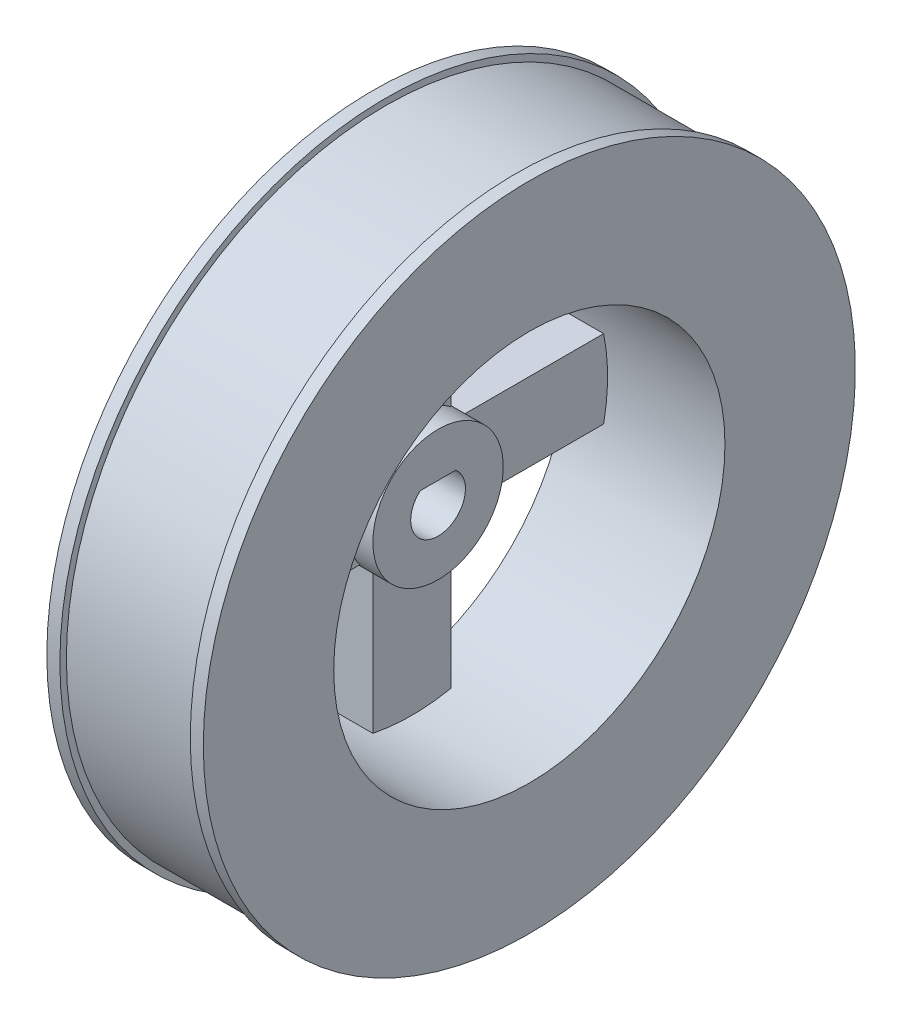
from build123d import *

# Parameters (mm, degrees)
SKETCH1_W               = 5
SKETCH1_H               = 5
BOSS_EXTRUDE1_DEPTH     = 3
CUT_EXTRUDE1_DEPTH      = 8
CUT_EXTRUDE1_DEPTH_BACK = 6
CIRPATTERN1_COUNT       = 4


with BuildPart() as part:
    # Sketch1 → Revolve1 (revolve)
    with BuildSketch(Plane.XY):
        Polygon((-6, 25), (-6, 15), (6, 15), (6, 25), (5, 25), (5, 24.5), (-5, 24.5), (-5, 25), align=None)
        with Locations((-3.5, 2.5)):
            Rectangle(SKETCH1_W, SKETCH1_H)
    revolve(axis=Axis((0, 0, 0), (1, 0, 0)))

    # Sketch2 → Boss-Extrude1 (add)
    with BuildSketch(Plane(origin=(-6, 0, 0), x_dir=(0, 0, -1), z_dir=(1, 0, 0))):
        with BuildLine():
            Line((-3, 4), (-3, 14.696938457))
            ThreePointArc((-3, 14.696938457), (0, 15), (3, 14.696938457))
            Line((3, 14.696938457), (3, 4))
            ThreePointArc((3, 4), (0, 5), (-3, 4))
        make_face()
    boss_extrude1 = extrude(amount=BOSS_EXTRUDE1_DEPTH)

    # Sketch3 → Cut-Extrude1 (cut, two sides)
    with BuildSketch(Plane(origin=(-1, 0, 0), x_dir=(0, 0, -1), z_dir=(1, 0, 0))) as cut_extrude1_sk:
        with BuildLine():
            Line((-1.360147051, 1.6), (1.360147051, 1.6))
            ThreePointArc((1.360147051, 1.6), (0, -2.1), (-1.360147051, 1.6))
        make_face()
    extrude(amount=CUT_EXTRUDE1_DEPTH, mode=Mode.SUBTRACT)
    extrude(cut_extrude1_sk.sketch, amount=-CUT_EXTRUDE1_DEPTH_BACK, mode=Mode.SUBTRACT)

    # CirPattern1: Boss-Extrude1 ×4 about axis
    cirpattern1_axis = Axis((0, 0, 0), (1, 0, 0))
    for i in range(1, CIRPATTERN1_COUNT):
        add(boss_extrude1.rotate(cirpattern1_axis, i * 360 / CIRPATTERN1_COUNT))


solid = part.part
